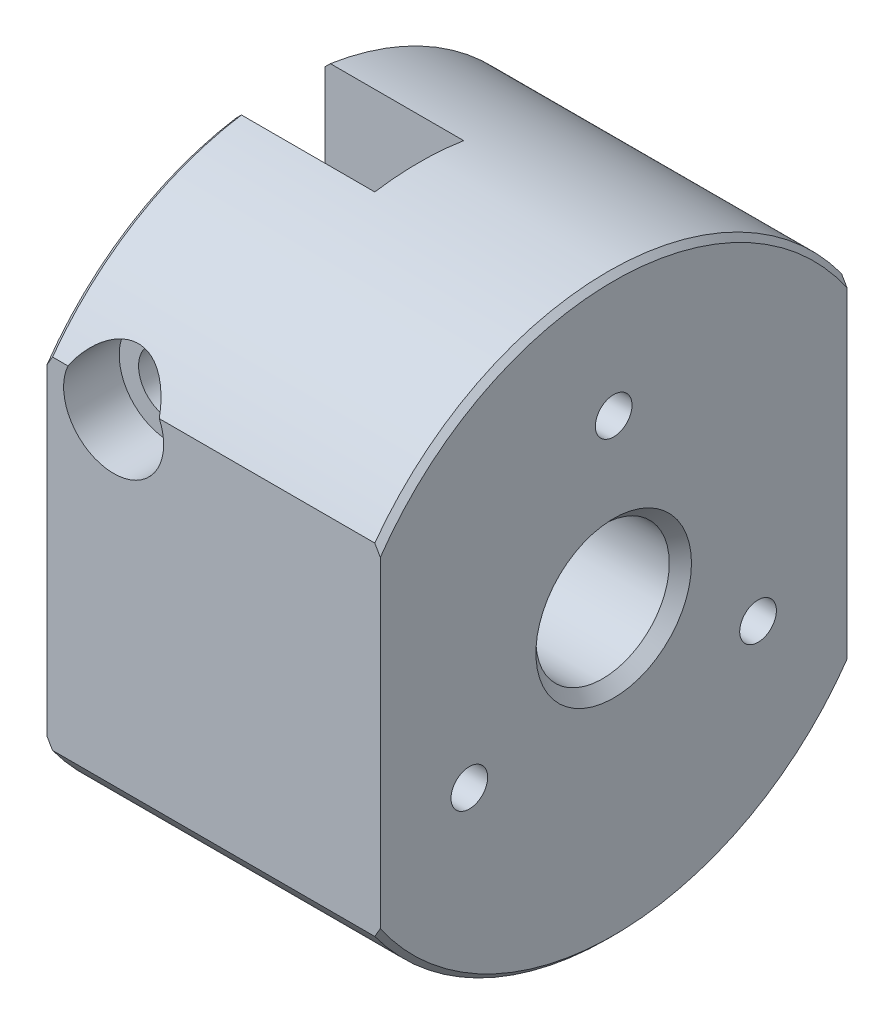
from build123d import *

# Parameters (mm, degrees)
BOSS_EXTRUDE1_DEPTH                     = 30
CUT_EXTRUDE1_DEPTH                      = 12.5
SKETCH3_W                               = 30
SKETCH3_H                               = 6
HOLE1_D                                 = 5.08
HOLE1_DEPTH                             = 8.413530316
HOLE1_TIP                               = 1.466469684
SKETCH6_W                               = 1.621
SKETCH6_H                               = 17
CBORE_FOR_M5_HEX_HEAD_BOLT1_D           = 5.5118
CBORE_FOR_M5_HEX_HEAD_BOLT1_DEPTH       = 17
CBORE_FOR_M5_HEX_HEAD_BOLT1_CBORE_D     = 9
CBORE_FOR_M5_HEX_HEAD_BOLT1_CBORE_DEPTH = 5
CHAMFER1_SIZE                           = 0.5
CHAMFER2_SIZE                           = 1
CHAMFER3_SIZE                           = 0.379
M4_TAPPED_HOLE1_D                       = 3.3
M4_TAPPED_HOLE1_DEPTH                   = 8
M4_TAPPED_HOLE1_TIP                     = 0.991420021


with BuildPart() as part:
    # Sketch1 → Boss-Extrude1 (new body)
    with BuildSketch(Plane(origin=(0, 0, 0), x_dir=(0, 0, -1), z_dir=(1, 0, 0))):
        with BuildLine():
            Line((21, -15.329709717), (21, 15.329709717))
            ThreePointArc((21, 15.329709717), (0, 26), (-21, 15.329709717))
            Line((-21, 15.329709717), (-21, -15.329709717))
            ThreePointArc((-21, -15.329709717), (0, -26), (21, -15.329709717))
        make_face()
    extrude(amount=-BOSS_EXTRUDE1_DEPTH)

    # Sketch2 → Cut-Extrude1 (cut)
    with BuildSketch(Plane.ZY.offset(30)):
        with BuildLine():
            Line((-4, 25.690465157), (-4, 4.472135955))
            ThreePointArc((-4, 4.472135955), (0, 6), (4, 4.472135955))
            Line((4, 4.472135955), (4, 25.690465157))
            ThreePointArc((4, 25.690465157), (0, 26), (-4, 25.690465157))
        make_face()
    extrude(amount=-CUT_EXTRUDE1_DEPTH, mode=Mode.SUBTRACT)

    # Sketch3 → Cut-Revolve1 (revolve, cut)
    with BuildSketch(Plane.XY):
        with Locations((-15, 3)):
            Rectangle(SKETCH3_W, SKETCH3_H)
    revolve(axis=Axis((-30, 0, 0), (1, 0, 0)), mode=Mode.SUBTRACT)

    # Hole1
    with Locations(Plane.ZY.offset(17.5)):
        with Locations((0, 21.27272472)):
            Hole(HOLE1_D / 2, depth=HOLE1_DEPTH)
            with Locations((0, 0, -(HOLE1_DEPTH + HOLE1_TIP / 2))):  # 120° drill point
                Cone(0, HOLE1_D / 2, HOLE1_TIP, mode=Mode.SUBTRACT)

    # Sketch6 → M3 Clearance Hole1 (revolve, cut)
    with BuildSketch(Plane(origin=(-24, 13.5, -4), x_dir=(0, -1, 0), z_dir=(1, 0, 0))):
        with Locations((0.8105, 8.5)):
            Rectangle(SKETCH6_W, SKETCH6_H)
    revolve(axis=Axis((-24, 13.5, 2.35), (0, 0, -1)), mode=Mode.SUBTRACT)

    # CBORE for M5 Hex Head Bolt1
    with Locations(Plane.XY.offset(21)):
        with Locations((-24, 13.5)):
            CounterBoreHole(CBORE_FOR_M5_HEX_HEAD_BOLT1_D / 2, CBORE_FOR_M5_HEX_HEAD_BOLT1_CBORE_D / 2, CBORE_FOR_M5_HEX_HEAD_BOLT1_CBORE_DEPTH, depth=CBORE_FOR_M5_HEX_HEAD_BOLT1_DEPTH)

    # Chamfer1
    chamfer1_edges = [part.edges().sort_by_distance(p)[0] for p in [
        (-30, 22.201659548, -13.530939115),
        (-30, 22.201659548, 13.530939115),
        (-30, -26, 0),
        (0, 26, 0),
        (0, -26, 0),
    ]]
    chamfer(chamfer1_edges, length=CHAMFER1_SIZE)

    # Chamfer2
    chamfer2_edges = [part.edges().sort_by_distance(p)[0] for p in [
        (-30, -6, 0),
        (0, -6, 0),
    ]]
    chamfer(chamfer2_edges, length=CHAMFER2_SIZE)

    # Chamfer3
    chamfer3_edges = [part.edges().sort_by_distance(p)[0] for p in [
        (-24, 15.121, -4),
    ]]
    chamfer(chamfer3_edges, length=CHAMFER3_SIZE)

    # M4 Tapped Hole1
    with Locations(Plane(origin=(0, 0, 0), x_dir=(0, 0, -1), z_dir=(1, 0, 0))):
        with Locations((0, 15), (12.990381057, -7.5), (-12.990381057, -7.5), (0, 0)):
            Hole(M4_TAPPED_HOLE1_D / 2, depth=M4_TAPPED_HOLE1_DEPTH)
            with Locations((0, 0, -(M4_TAPPED_HOLE1_DEPTH + M4_TAPPED_HOLE1_TIP / 2))):  # 118° drill point
                Cone(0, M4_TAPPED_HOLE1_D / 2, M4_TAPPED_HOLE1_TIP, mode=Mode.SUBTRACT)


solid = part.part
